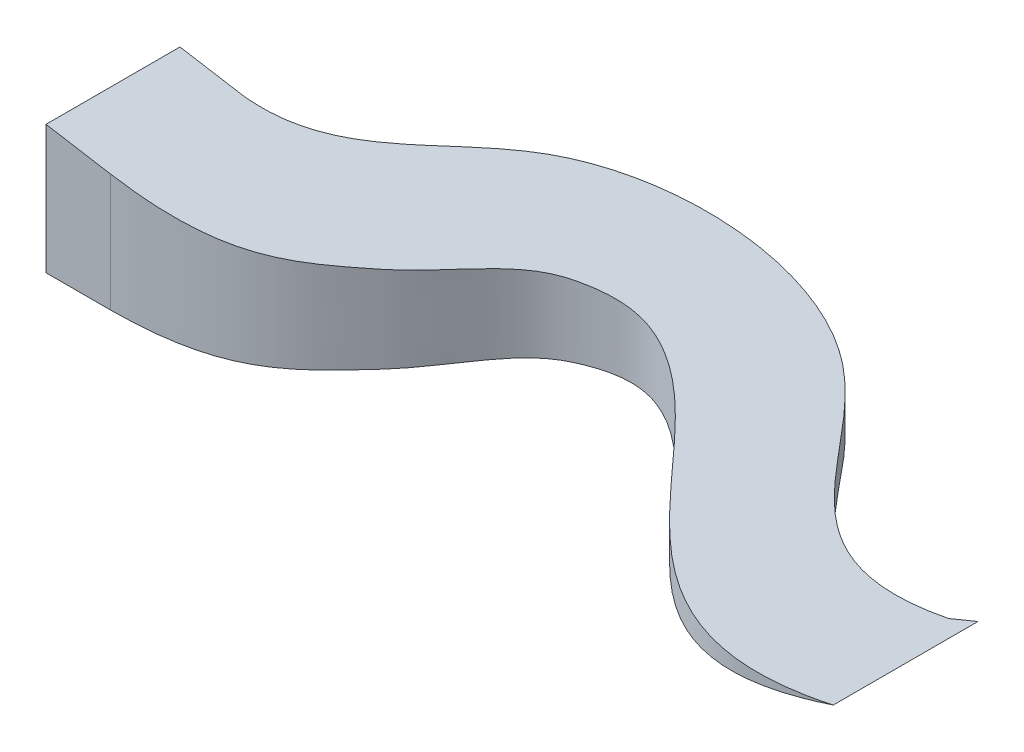
from build123d import *

# Parameters (mm, degrees)
BOSS_EXTRUDE1_DEPTH     = 600
CUT_EXTRUDE1_DEPTH      = 1980
CUT_EXTRUDE1_DEPTH_BACK = 1980


with BuildPart() as part:
    # Sketch3 → Boss-Extrude1 (new body)
    with BuildSketch(Plane(origin=(0, 0, 0), x_dir=(1, 0, 0), z_dir=(0, 1, 0))):
        with BuildLine():
            Line((103.218681112, 620), (-196.781318888, 620))
            Line((-196.781318888, 620), (-196.781318888, -5))
            Line((-196.781318888, -5), (103.218681112, -5))
            add(Edge.make_bspline(
                [(103.218681112, -5), (588.195154083, -3.163876673), (771.964594842, 163.799162942), (1094.072701401, 516.961291923), (1231.556596444, 783.162980701), (1553.46181428, 941.694369248), (2236.258983329, 839.954455387), (2563.06483301, -321.158582751), (3386.238883814, 85.06610873)],
                knots=[0, 0, 0, 0, 0.169189831, 0.199378197, 0.290494168, 0.314771929, 0.430766308, 1, 1, 1, 1], degree=3))
            Line((3386.238883814, 85.06610873), (3386.238883814, 760.246183749))
            add(Edge.make_bspline(
                [(3386.238883814, 760.246183749), (3317.035378353, 692.028174156)],
                knots=[0, 0, 1, 1], degree=1))
            add(Edge.make_bspline(
                [(3317.035378353, 692.028174156), (2719.285403286, 421.343297775), (2458.958585868, 1613.401027739), (791.345221602, 1472.71065196), (517.504039845, 642.649574707), (103.218681112, 620)],
                knots=[0, 0, 0, 0, 0.371433836, 0.717359921, 1, 1, 1, 1], degree=3))
        make_face()
    extrude(amount=BOSS_EXTRUDE1_DEPTH)

    # Sketch4 → Cut-Extrude1 (cut, two sides)
    with BuildSketch(Plane.XY) as cut_extrude1_sk:
        Polygon((-196.781318888, 600), (3386.238883814, 0), (3386.238883814, 600), align=None)
    extrude(amount=CUT_EXTRUDE1_DEPTH, mode=Mode.SUBTRACT)
    extrude(cut_extrude1_sk.sketch, amount=-CUT_EXTRUDE1_DEPTH_BACK, mode=Mode.SUBTRACT)


solid = part.part
